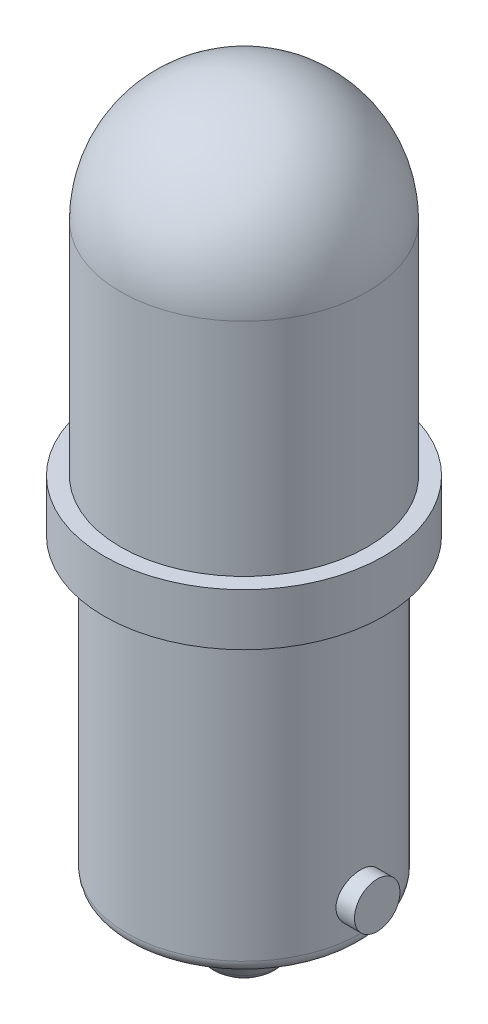
from build123d import *

# Parameters (mm, degrees)
SKETCH2_R           = 4.826
BOSS_EXTRUDE1_DEPTH = 15.494
FILLET1_R           = 4.826
SKETCH3_R           = 5.461
BOSS_EXTRUDE2_DEPTH = 2.032
SKETCH4_R           = 4.572
BOSS_EXTRUDE3_DEPTH = 11.684
SKETCH5_R           = 2.921
BOSS_EXTRUDE4_DEPTH = 2.794
BOSS_EXTRUDE4_TAPER = 35
FILLET2_R           = 1.27
FILLET3_R           = 0.508
SKETCH6_R           = 0.889
BOSS_EXTRUDE5_DEPTH = 5.207


with BuildPart() as part:
    # Sketch2 → Boss-Extrude1 (new body)
    with BuildSketch(Plane(origin=(0, 0, 0), x_dir=(1, 0, 0), z_dir=(0, 1, 0))):
        with Locations(Location((0, 0, 0), (0, 0, 270))):  # turned: the seam where the file's is
            Circle(SKETCH2_R)
    extrude(amount=BOSS_EXTRUDE1_DEPTH)

    # Fillet1
    fillet1_edges = [part.edges().sort_by_distance(p)[0] for p in [
        (0, 15.494, -4.826),
    ]]
    fillet(fillet1_edges, radius=FILLET1_R)

    # Sketch3 → Boss-Extrude2 (add)
    with BuildSketch(Plane.XZ):
        with Locations(Location((0, 0, 0), (0, 0, 270))):  # turned: the seam where the file's is
            Circle(SKETCH3_R)
    extrude(amount=-BOSS_EXTRUDE2_DEPTH)

    # Sketch4 → Boss-Extrude3 (add)
    with BuildSketch(Plane.XZ):
        with Locations(Location((0, 0, 0), (0, 0, 90))):  # turned: the seam where the file's is
            Circle(SKETCH4_R)
    extrude(amount=BOSS_EXTRUDE3_DEPTH)

    # Sketch5 → Boss-Extrude4 (add)
    with BuildSketch(Plane.XZ.offset(11.684)):
        Circle(SKETCH5_R)
    extrude(amount=BOSS_EXTRUDE4_DEPTH, taper=BOSS_EXTRUDE4_TAPER)

    # Fillet2
    fillet2_edges = [part.edges().sort_by_distance(p)[0] for p in [
        (-0.964620138, -14.478, 0),
    ]]
    fillet(fillet2_edges, radius=FILLET2_R)

    # Fillet3
    fillet3_edges = [part.edges().sort_by_distance(p)[0] for p in [
        (0, -11.684, -4.572),
    ]]
    fillet(fillet3_edges, radius=FILLET3_R)

    # Sketch6 → Boss-Extrude5 (add, symmetric)
    with BuildSketch(Plane(origin=(0, 0, 0), x_dir=(0, 0, -1), z_dir=(1, 0, 0))):
        with Locations(Location((0, -9.906, 0), (0, 0, 180))):  # turned: the seam where the file's is
            Circle(SKETCH6_R)
    extrude(amount=BOSS_EXTRUDE5_DEPTH, both=True)


solid = part.part
